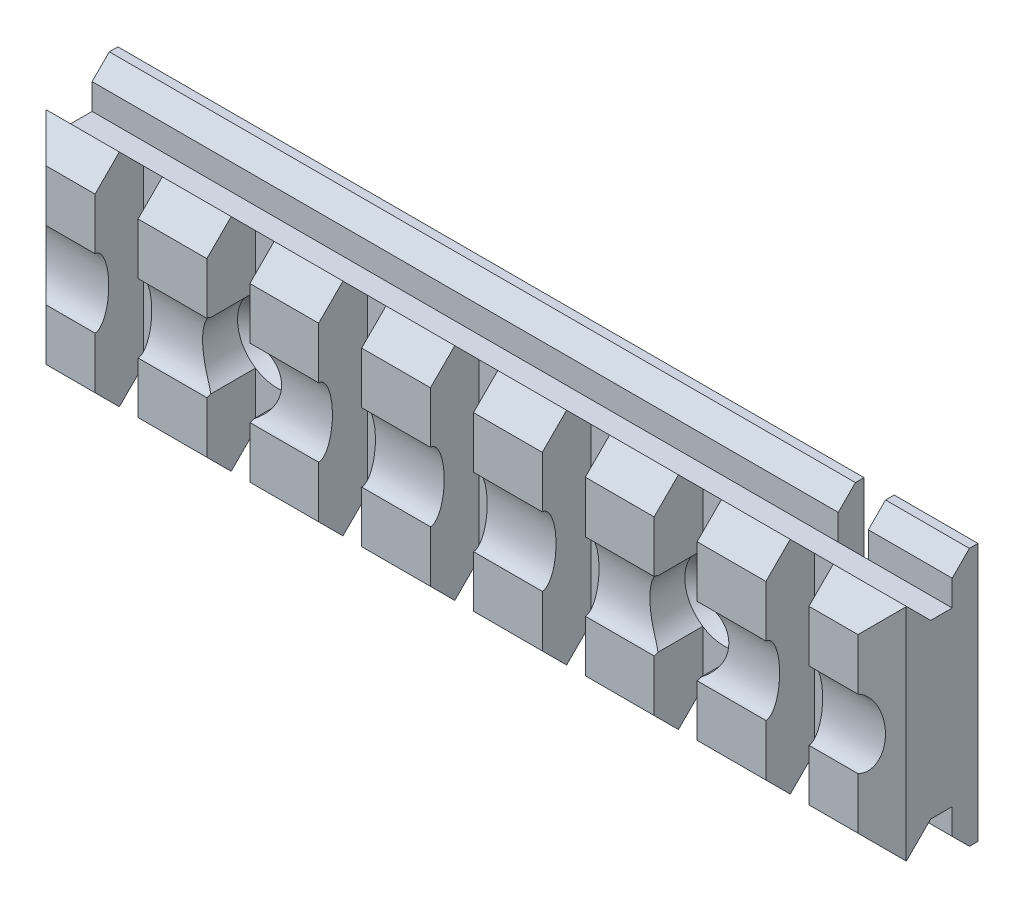
from build123d import *

# Parameters (mm, degrees)
SKIZZE1_W                                   = 100
SKIZZE1_H                                   = 30
AUFSATZ_LINEAR_AUSTRAGEN1_DEPTH             = 3
SKIZZE4_W                                   = 100
SKIZZE4_H                                   = 20
AUFSATZ_LINEAR_AUSTRAGEN2_DEPTH             = 2.5
AUFSATZ_LINEAR_AUSTRAGEN3_DEPTH             = 100
FASE1_SIZE                                  = 2.8
FASE2_SIZE                                  = 2.8
SKIZZE8_W                                   = 5
SKIZZE8_H                                   = 25.656854249
SCHNITT_LINEAR_AUSTRAGEN1_DEPTH             = 5.656854
LINEARES_MUSTER1_COUNT                      = 7
LINEARES_MUSTER1_PITCH                      = 13
FASE3_SIZE                                  = 2
FASE4_SIZE                                  = 2
FORMSENKUNG_F_R_M4_SENKSCHRAUBE_MIT_2_COUNT = 2
FORMSENKUNG_F_R_M4_SENKSCHRAUBE_MIT_2_PITCH = 52
SKIZZE13_RX                                 = 4
SKIZZE13_RY                                 = 1.6
SCHNITT_LINEAR_AUSTRAGEN2_DEPTH             = 101
SKIZZE14_R                                  = 4.59
SCHNITT_LINEAR_AUSTRAGEN3_DEPTH             = 5.656854
SKIZZE15_W                                  = 3.5
SKIZZE15_H                                  = 11.5
SCHNITT_LINEAR_AUSTRAGEN4_DEPTH             = 3


with BuildPart() as part:
    # Skizze1 → Aufsatz-Linear austragen1 (new body)
    with BuildSketch(Plane.XY):
        with Locations((11.40731351, 6.392153494)):
            Rectangle(SKIZZE1_W, SKIZZE1_H)
    extrude(amount=AUFSATZ_LINEAR_AUSTRAGEN1_DEPTH)

    # Skizze4 → Aufsatz-Linear austragen2 (add)
    with BuildSketch(Plane.XY.offset(3)):
        with Locations((11.40731351, 6.392153494)):
            Rectangle(SKIZZE4_W, SKIZZE4_H)
    extrude(amount=AUFSATZ_LINEAR_AUSTRAGEN2_DEPTH)

    # Skizze7 → Aufsatz-Linear austragen3 (add)
    with BuildSketch(Plane(origin=(61.40731351, 0, 0), x_dir=(0, 0, -1), z_dir=(1, 0, 0))):
        Polygon((-5.5, 16.392153494), (-8.328427125, 19.220580618), (-11.156854249, 16.392153494), (-11.156854249, -3.607846506), (-8.328427125, -6.436273631), (-5.5, -3.607846506), align=None)
    extrude(amount=-AUFSATZ_LINEAR_AUSTRAGEN3_DEPTH)

    # Fase1
    fase1_edges = [part.edges().sort_by_distance(p)[0] for p in [
        (61.40731351, 6.392153494, 11.156854249),
    ]]
    chamfer(fase1_edges, length=FASE1_SIZE)

    # Fase2
    fase2_edges = [part.edges().sort_by_distance(p)[0] for p in [
        (-38.59268649, 6.392153494, 11.156854249),
    ]]
    chamfer(fase2_edges, length=FASE2_SIZE)

    # Skizze8 → Schnitt-Linear austragen1 (cut)
    with BuildSketch(Plane.XY.offset(11.156854249)):
        with Locations((-27.59268649, 6.392153493)):
            Rectangle(SKIZZE8_W, SKIZZE8_H)
    schnitt_linear_austragen1 = extrude(amount=-SCHNITT_LINEAR_AUSTRAGEN1_DEPTH, mode=Mode.SUBTRACT)

    # Lineares Muster1: Schnitt-Linear austragen1 ×7
    with Locations(*[(i * LINEARES_MUSTER1_PITCH, 0, 0) for i in range(1, LINEARES_MUSTER1_COUNT)]):
        add(schnitt_linear_austragen1, mode=Mode.SUBTRACT)

    # Fase3
    fase3_edges = [part.edges().sort_by_distance(p)[0] for p in [
        (11.40731351, 21.392153494, 3),
    ]]
    chamfer(fase3_edges, length=FASE3_SIZE)

    # Fase4
    fase4_edges = [part.edges().sort_by_distance(p)[0] for p in [
        (11.40731351, -8.607846506, 3),
    ]]
    chamfer(fase4_edges, length=FASE4_SIZE)

    # Skizze9 → Formsenkung für M4 Senkschraube mit Innensechskant1 (revolve, cut)
    with BuildSketch(Plane(origin=(-14.59268649, 6.392153494, 5.5), x_dir=(0, -1, 0), z_dir=(1, 0, 0))):
        Polygon((0, 0), (0, 5.5), (2.25, 5.5), (2.25, 2.34), (4.59, 0), align=None)
    formsenkung_f_r_m4_senkschraube_mit_inne = revolve(axis=Axis((-14.59268649, 6.392153494, 11.85), (0, 0, -1)), mode=Mode.SUBTRACT)

    # Formsenkung f_r M4 Senkschraube mit  2: Formsenkung für M4 Senkschraube mit Innensechskant1 ×2
    with Locations(*[(i * FORMSENKUNG_F_R_M4_SENKSCHRAUBE_MIT_2_PITCH, 0, 0) for i in range(1, FORMSENKUNG_F_R_M4_SENKSCHRAUBE_MIT_2_COUNT)]):
        add(formsenkung_f_r_m4_senkschraube_mit_inne, mode=Mode.SUBTRACT)

    # Skizze13 → Schnitt-Linear austragen2 (cut, through all)
    with BuildSketch(Plane(origin=(61.40731351, 0, 0), x_dir=(0, 0, -1), z_dir=(1, 0, 0))):
        with Locations(Location((-11.156854249, 6.392153494), (0, 0, 90))):
            Ellipse(SKIZZE13_RX, SKIZZE13_RY)
    extrude(amount=-SCHNITT_LINEAR_AUSTRAGEN2_DEPTH, mode=Mode.SUBTRACT)

    # Skizze14 → Schnitt-Linear austragen3 (cut)
    with BuildSketch(Plane.XY.offset(5.5)):
        with Locations((37.40731351, 6.392153494)):
            Circle(SKIZZE14_R)
        with Locations((-14.59268649, 6.392153494)):
            Circle(SKIZZE14_R)
    extrude(amount=SCHNITT_LINEAR_AUSTRAGEN3_DEPTH, mode=Mode.SUBTRACT)

    # Skizze15 → Schnitt-Linear austragen4 (cut)
    with BuildSketch(Plane(origin=(0, 0, 0), x_dir=(-1, 0, 0), z_dir=(0, 0, -1))):
        with Locations((-49.90731351, 15.642153494)):
            Rectangle(SKIZZE15_W, SKIZZE15_H)
    extrude(amount=-SCHNITT_LINEAR_AUSTRAGEN4_DEPTH, mode=Mode.SUBTRACT)


solid = part.part
